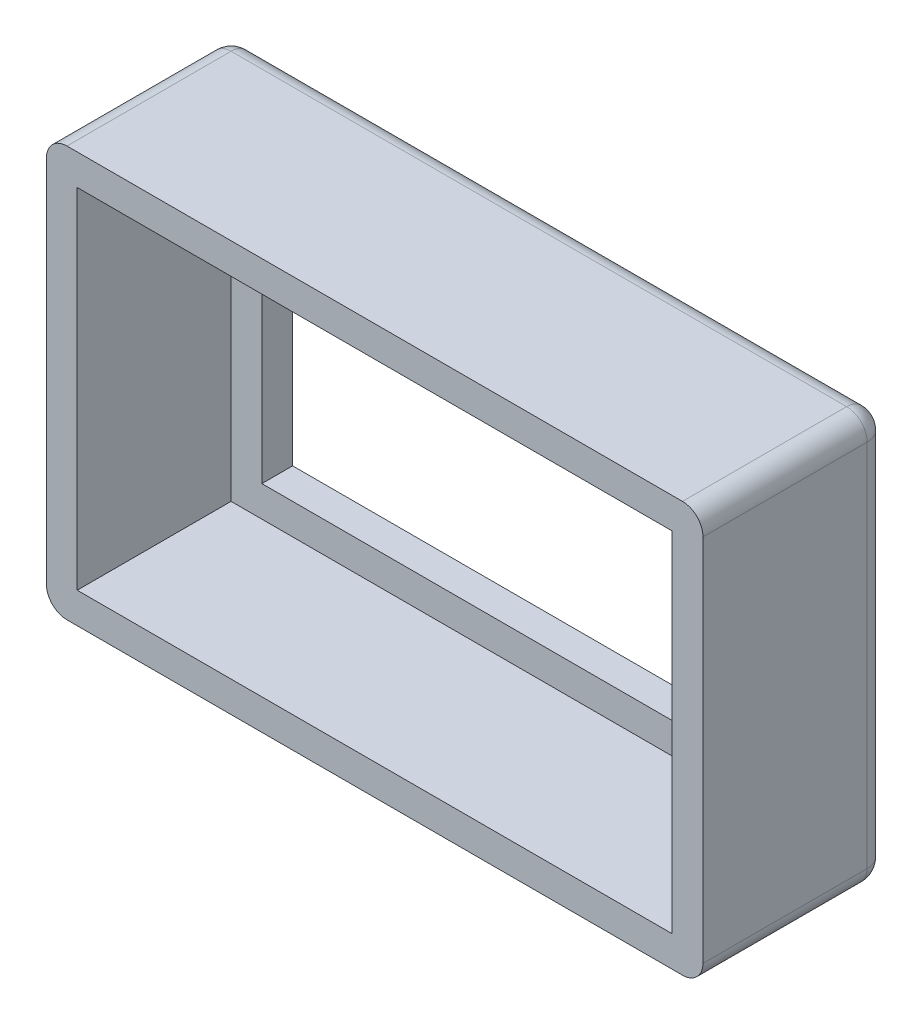
from build123d import *

# Parameters (mm, degrees)
SKETCH1_W           = 16.256
SKETCH1_H           = 10.16
SKETCH1_W_2         = 13.208
SKETCH1_H_2         = 7.112
BOSS_EXTRUDE1_DEPTH = 4.572
SKETCH2_W           = 14.732
SKETCH2_H           = 8.636
CUT_EXTRUDE1_DEPTH  = 3.81
FILLET1_R           = 0.508


with BuildPart() as part:
    # Sketch1 → Boss-Extrude1 (new body)
    with BuildSketch(Plane.XY):
        with Locations((22.86, -62.992)):
            Rectangle(SKETCH1_W, SKETCH1_H)
        with Locations((22.86, -62.992)):
            Rectangle(SKETCH1_W_2, SKETCH1_H_2, mode=Mode.SUBTRACT)
    extrude(amount=-BOSS_EXTRUDE1_DEPTH)

    # Sketch2 → Cut-Extrude1 (cut)
    with BuildSketch(Plane.XY):
        with Locations((22.86, -62.992)):
            Rectangle(SKETCH2_W, SKETCH2_H)
    extrude(amount=-CUT_EXTRUDE1_DEPTH, mode=Mode.SUBTRACT)

    # Fillet1
    fillet1_edges = [part.edges().sort_by_distance(p)[0] for p in [
        (14.732, -62.992, -4.572),
        (22.86, -68.072, -4.572),
        (30.988, -62.992, -4.572),
        (22.86, -57.912, -4.572),
        (30.988, -68.072, -2.286),
        (14.732, -68.072, -2.286),
        (14.732, -57.912, -2.286),
        (30.988, -57.912, -2.286),
    ]]
    fillet(fillet1_edges, radius=FILLET1_R)


solid = part.part
